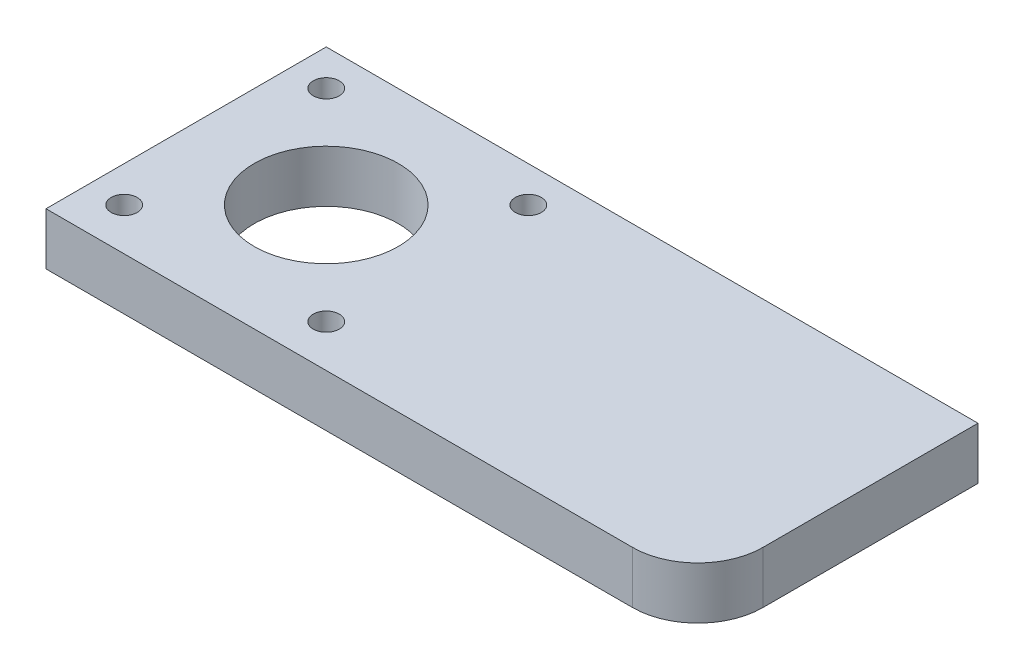
from build123d import *

# Parameters (mm, degrees)
SKETCH_1_R      = 11.05
SKETCH_1_R_2    = 2
EXTRUDE_1_DEPTH = 8


with BuildPart() as part:
    # Эскиз1 → Бобышка-Вытянуть1 (new body)
    with BuildSketch(Plane(origin=(0, 0, 0), x_dir=(1, 0, 0), z_dir=(0, 1, 0))):
        with BuildLine():
            Line((-50, -21.5), (40, -21.5))
            ThreePointArc((40, -21.5), (47.071067812, -18.571067812), (50, -11.5))
            Line((50, -11.5), (50, 21.5))
            Line((50, 21.5), (-50, 21.5))
            Line((-50, 21.5), (-50, -21.5))
        make_face()
        with Locations((-29, 0.5)):
            Circle(SKETCH_1_R, mode=Mode.SUBTRACT)
        with Locations((-13.5, -15)):
            Circle(SKETCH_1_R_2, mode=Mode.SUBTRACT)
        with Locations((-13.5, 16)):
            Circle(SKETCH_1_R_2, mode=Mode.SUBTRACT)
        with Locations((-44.5, -15)):
            Circle(SKETCH_1_R_2, mode=Mode.SUBTRACT)
        with Locations((-44.5, 16)):
            Circle(SKETCH_1_R_2, mode=Mode.SUBTRACT)
    extrude(amount=EXTRUDE_1_DEPTH)


solid = part.part
